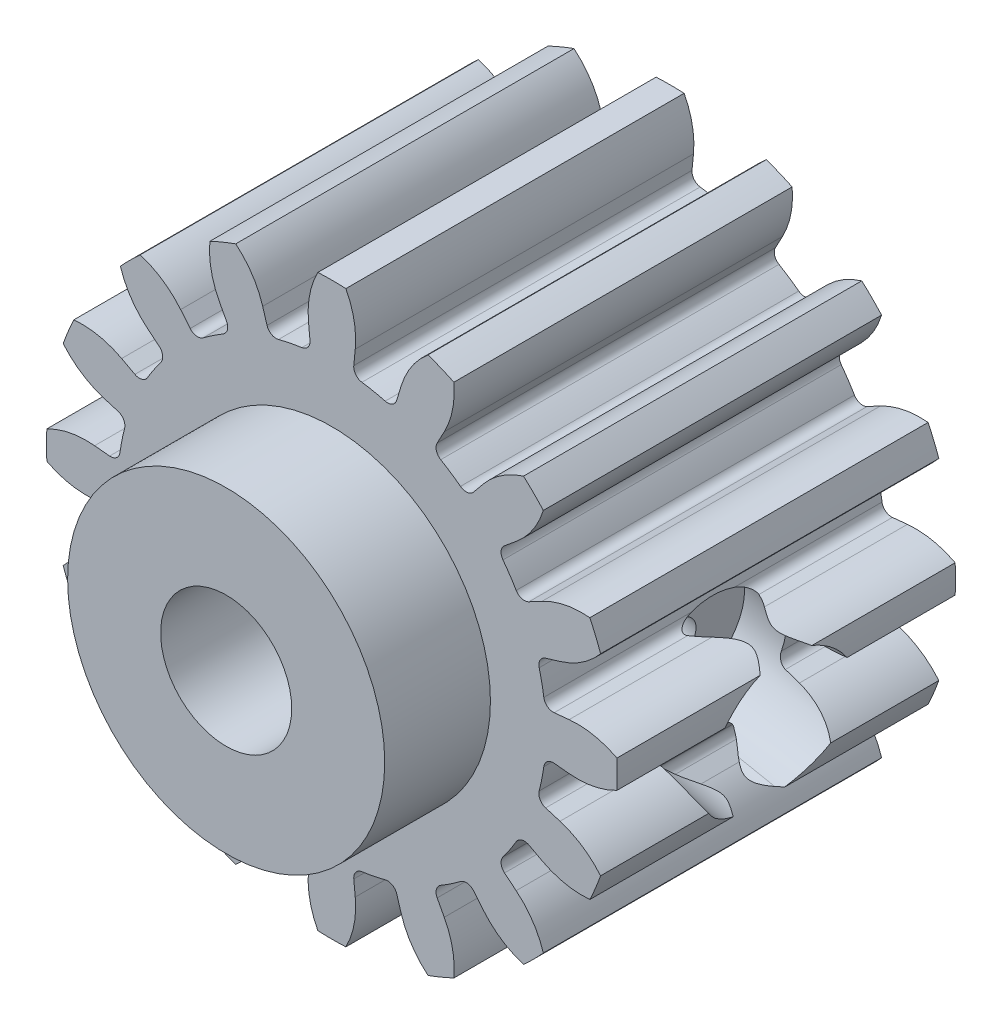
from build123d import *

# Parameters (mm, degrees)
MAINGEAR_DEPTH                     = 8
CONG_1_R                           = 0.45
R_P_TITION_CIRCULAIRE1_COUNT       = 16
CONG_1_OF_R_P_TITION_CIRCULAIRE1_R = 0.45
ESQUISSE9_R                        = 7.5
ESQUISSE9_R_2                      = 3.1
GEARBOTTOMFIX_DEPTH                = 5
ESQUISSE3_R                        = 3.1
GEARHOLE_DEPTH                     = 29.381331893
CUT_EXTRUDE2_DEPTH                 = 24.097618925
CUT_EXTRUDE2_DEPTH_BACK            = 24.097618925
SKETCH1_R                          = 1.25
SKETCH2_R                          = 3.5
CUT_EXTRUDE3_DEPTH                 = 30.269819976


with BuildPart() as part:
    # Esquisse1 → MainGear (new, symmetric)
    with BuildSketch(Plane.XY):
        with BuildLine():
            Line((0, 0), (9.930450964, 1.97528951))
            ThreePointArc((9.930450964, 1.97528951), (10.015412163, 1.485646054), (10.076245358, 0.992423546))
            Line((10.076245358, 0.992423546), (11.222012928, 1.105271802))
            ThreePointArc((11.222012928, 1.105271802), (12.385383401, 1.049862646), (13.483738659, 0.662413603))
            ThreePointArc((13.483738659, 0.662413603), (13.5, 0), (13.483738659, -0.662413603))
            ThreePointArc((13.483738659, -0.662413603), (12.385383401, -1.049862646), (11.222012928, -1.105271802))
            Line((11.222012928, -1.105271802), (10.076245358, -0.992423546))
            ThreePointArc((10.076245358, -0.992423546), (10.015412163, -1.485646054), (9.930450964, -1.97528951))
            Line((9.930450964, -1.97528951), (0, 0))
        make_face()
    maingear = extrude(amount=MAINGEAR_DEPTH, both=True)

    # Congé1
    cong_1_edges = [part.edges().sort_by_distance(p)[0] for p in [
        (10.076245358, -0.992423546, 0),
        (10.076245358, 0.992423546, 0),
    ]]
    fillet(cong_1_edges, radius=CONG_1_R)

    # Répétition circulaire1: MainGear ×16 about axis
    r_p_tition_circulaire1_axis = Axis((0, 0, 8), (0, 0, -1))
    for i in range(1, R_P_TITION_CIRCULAIRE1_COUNT):
        add(maingear.rotate(r_p_tition_circulaire1_axis, i * 360 / R_P_TITION_CIRCULAIRE1_COUNT))

    # Congé1 of Répétition circulaire1
    cong_1_of_r_p_tition_circulaire1_edges = [part.edges().sort_by_distance(p)[0] for p in [
        (8.929452802, -4.77289196, 0),
        (9.689020899, -2.939132357, 0),
        (6.423232002, -7.82673084, 0),
        (7.82673084, -6.423232002, 0),
        (2.939132357, -9.689020899, 0),
        (4.77289196, -8.929452802, 0),
        (-0.992423546, -10.076245358, 0),
        (0.992423546, -10.076245358, 0),
        (-4.77289196, -8.929452802, 0),
        (-2.939132357, -9.689020899, 0),
        (-7.82673084, -6.423232002, 0),
        (-6.423232002, -7.82673084, 0),
        (-9.689020899, -2.939132357, 0),
        (-8.929452802, -4.77289196, 0),
        (-10.076245358, 0.992423546, 0),
        (-10.076245358, -0.992423546, 0),
        (-8.929452802, 4.77289196, 0),
        (-9.689020899, 2.939132357, 0),
        (-6.423232002, 7.82673084, 0),
        (-7.82673084, 6.423232002, 0),
        (-2.939132357, 9.689020899, 0),
        (-4.77289196, 8.929452802, 0),
        (0.992423546, 10.076245358, 0),
        (-0.992423546, 10.076245358, 0),
        (4.77289196, 8.929452802, 0),
        (2.939132357, 9.689020899, 0),
        (7.82673084, 6.423232002, 0),
        (6.423232002, 7.82673084, 0),
        (9.689020899, 2.939132357, 0),
        (8.929452802, 4.77289196, 0),
    ]]
    fillet(cong_1_of_r_p_tition_circulaire1_edges, radius=CONG_1_OF_R_P_TITION_CIRCULAIRE1_R)

    # Esquisse9 → GearBottomFix (add)
    with BuildSketch(Plane.XY.offset(8)):
        Circle(ESQUISSE9_R)
        Circle(ESQUISSE9_R_2, mode=Mode.SUBTRACT)
    extrude(amount=GEARBOTTOMFIX_DEPTH)

    # Esquisse3 → GearHole (cut, through all)
    with BuildSketch(Plane.XY.offset(-8)):
        Circle(ESQUISSE3_R)
    extrude(amount=GEARHOLE_DEPTH, mode=Mode.SUBTRACT)

    # Sketch1 → Cut-Extrude2 (cut, two sides: drawn at the far end of the back side and taken through both)
    with BuildSketch(Plane(origin=(0, 0, 0), x_dir=(0, 0, -1), z_dir=(0.9807852804032304, -0.19509032201612872, 0)).offset(-CUT_EXTRUDE2_DEPTH_BACK)):
        Circle(SKETCH1_R)
    extrude(amount=CUT_EXTRUDE2_DEPTH + CUT_EXTRUDE2_DEPTH_BACK, mode=Mode.SUBTRACT)

    # Sketch2 → Cut-Extrude3 (cut, through all)
    with BuildSketch(Plane(origin=(7.953530242, -1.582055529, 0), x_dir=(0, 0, -1), z_dir=(0.9807852804032304, -0.1950903220161287, 0))):
        Circle(SKETCH2_R)
    extrude(amount=CUT_EXTRUDE3_DEPTH, mode=Mode.SUBTRACT)


solid = part.part
